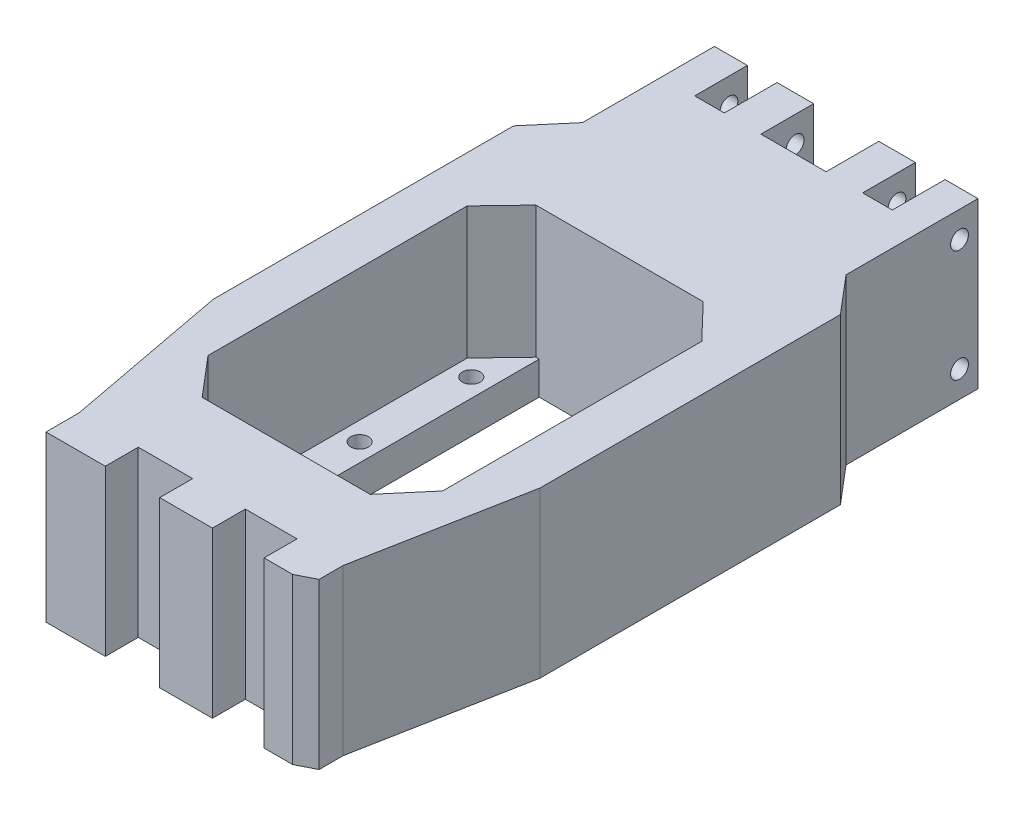
from build123d import *

# Parameters (mm, degrees)
SZKIC1_W                    = 24.4
SZKIC1_H                    = 45
SZKIC1_R                    = 1.35
DODANIE_WYCI_GNI_CIE1_DEPTH = 5
DODANIE_WYCI_GNI_CIE2_DEPTH = 25
SZKIC8_W                    = 8
SZKIC8_H                    = 5
SZKIC8_W_2                  = 9
DODANIE_WYCI_GNI_CIE3_DEPTH = 25
SZKIC7_R                    = 1.35
WYTNIJ_WYCI_GNI_CIE8_DEPTH  = 161.231596245


with BuildPart() as part:
    # Szkic1 → Dodanie-wyci_gni_cie1 (new body)
    with BuildSketch(Plane(origin=(0, 0, 0), x_dir=(1, 0, 0), z_dir=(0, 1, 0))):
        Polygon((14.547789553, 143.7963255), (10.047789553, 143.7963255), (10.047789553, 151.7963255), (4.495079248, 151.7963255), (4.495079248, 143.7963255), (-5.399500142, 143.7963255), (-5.399500142, 151.7963255), (-10.952210447, 151.7963255), (-10.952210447, 143.7963255), (-15.452210447, 143.7963255), (-15.452210447, 151.7963255), (-20.452210447, 151.7963255), (-20.452210447, 131.76713902), (-25.252210447, 126.117958863), (-25.252210447, 80.533497461), (-20.5, 55.3963255), (19.595579106, 55.3963255), (24.347789553, 80.533497461), (24.347789553, 126.117958863), (19.547789553, 131.76713902), (19.547789553, 151.7963255), (14.547789553, 151.7963255), align=None)
        with Locations((-0.452210447, 94.8963255)):
            Rectangle(SZKIC1_W, SZKIC1_H, mode=Mode.SUBTRACT)
        with Locations((14.547789553, 109.8963255)):
            Circle(SZKIC1_R, mode=Mode.SUBTRACT)
        with Locations((-15.404420894, 75.8963255)):
            Circle(SZKIC1_R, mode=Mode.SUBTRACT)
        with Locations((-8.952210447, 69.5963255)):
            Circle(SZKIC1_R, mode=Mode.SUBTRACT)
        with Locations((-15.404420894, 92.8963255)):
            Circle(SZKIC1_R, mode=Mode.SUBTRACT)
        with Locations((8.047789553, 69.5963255)):
            Circle(SZKIC1_R, mode=Mode.SUBTRACT)
        with Locations((14.5, 75.8963255)):
            Circle(SZKIC1_R, mode=Mode.SUBTRACT)
        with Locations((14.5, 92.8963255)):
            Circle(SZKIC1_R, mode=Mode.SUBTRACT)
        with Locations((-15.452210447, 109.8963255)):
            Circle(SZKIC1_R, mode=Mode.SUBTRACT)
    extrude(amount=DODANIE_WYCI_GNI_CIE1_DEPTH)

    # Szkic1_3 → Dodanie-wyci_gni_cie2 (add)
    with BuildSketch(Plane(origin=(0, 0, 0), x_dir=(1, 0, 0), z_dir=(0, 1, 0))):
        Polygon((14.547789553, 143.7963255), (10.047789553, 143.7963255), (10.047789553, 151.7963255), (4.495079248, 151.7963255), (4.495079248, 143.7963255), (-5.399500142, 143.7963255), (-5.399500142, 151.7963255), (-10.952210447, 151.7963255), (-10.952210447, 143.7963255), (-15.452210447, 143.7963255), (-15.452210447, 151.7963255), (-20.452210447, 151.7963255), (-20.452210447, 131.76713902), (-25.252210447, 126.117958863), (-25.252210447, 80.533497461), (-20.5, 55.3963255), (19.595579106, 55.3963255), (24.347789553, 80.533497461), (24.347789553, 126.117958863), (19.547789553, 131.76713902), (19.547789553, 151.7963255), (14.547789553, 151.7963255), align=None)
        Polygon((-13.152210447, 117.3963255), (-12.652210447, 117.3963255), (11.747789553, 117.3963255), (12.247789553, 117.3963255), (17.347789553, 112.070622628), (17.347789553, 72.740102496), (12.295579106, 66.7963255), (-13.2, 66.7963255), (-18.252210447, 72.740102496), (-18.252210447, 112.070622628), align=None, mode=Mode.SUBTRACT)
    extrude(amount=DODANIE_WYCI_GNI_CIE2_DEPTH)

    # Szkic8 → Dodanie-wyci_gni_cie3 (add)
    with BuildSketch(Plane(origin=(0, 25, 0), x_dir=(1, 0, 0), z_dir=(0, 1, 0))):
        Polygon((19.595579106, 51.744454691), (19.595579106, 55.3963255), (12.595579106, 55.3963255), (12.595579106, 50.3963255), (16.925579106, 50.3963255), align=None)
        with Locations((0.758846465, 52.8963255)):
            Rectangle(SZKIC8_W, SZKIC8_H)
        with Locations((-16, 52.8963255)):
            Rectangle(SZKIC8_W_2, SZKIC8_H)
    extrude(amount=-DODANIE_WYCI_GNI_CIE3_DEPTH)

    # Szkic7 → Wytnij-wyci_gni_cie8 (cut, through all)
    with BuildSketch(Plane.ZY.offset(20.452210447)):
        with Locations((-148.9963255, 21)):
            Circle(SZKIC7_R)
        with Locations((-148.9963255, 4)):
            Circle(SZKIC7_R)
    extrude(amount=-WYTNIJ_WYCI_GNI_CIE8_DEPTH, mode=Mode.SUBTRACT)


solid = part.part
